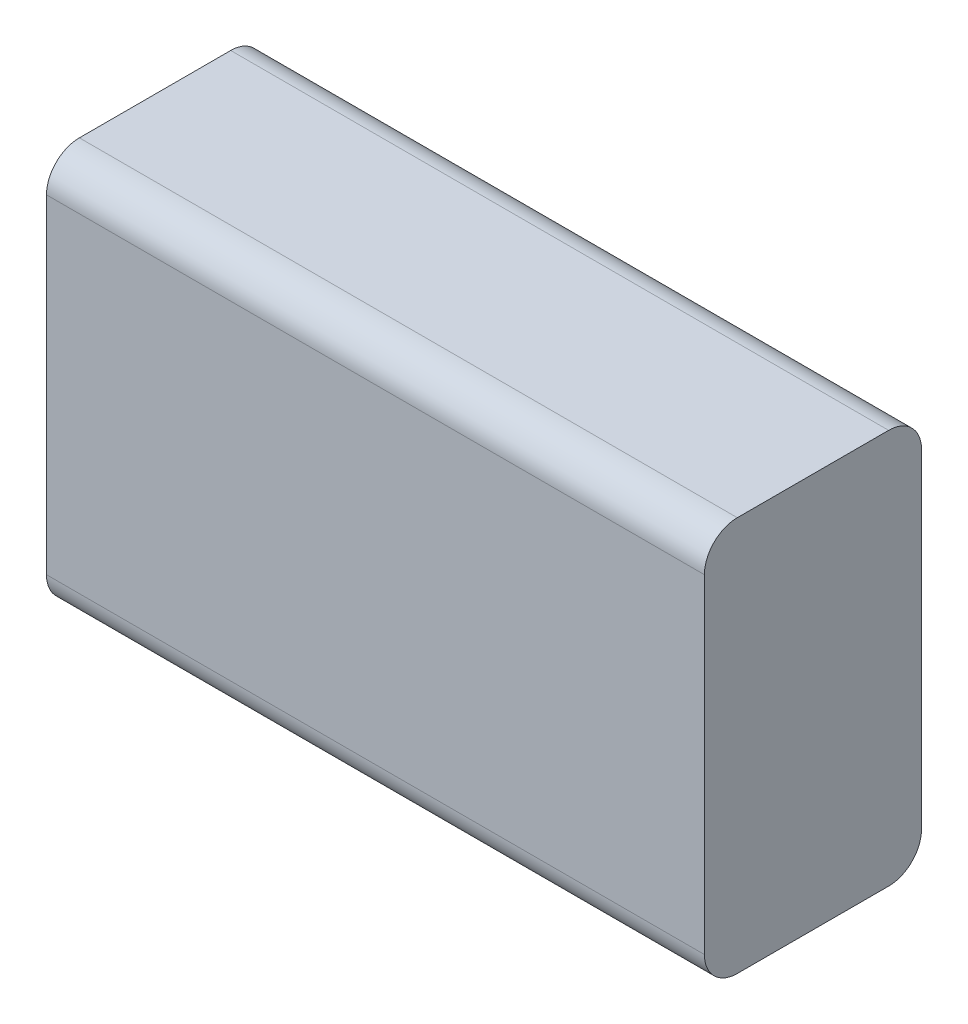
from build123d import *

# Parameters (mm, degrees)
SKETCH1_W           = 1
SKETCH1_H           = 0.33
BOSS_EXTRUDE1_DEPTH = 0.6
FILLET2_R           = 0.05


with BuildPart() as part:
    # Sketch1 → Boss-Extrude1 (new body)
    with BuildSketch(Plane(origin=(0, 0, 0), x_dir=(1, 0, 0), z_dir=(0, 1, 0))):
        with Locations((0.5, -0.165)):
            Rectangle(SKETCH1_W, SKETCH1_H)
    extrude(amount=BOSS_EXTRUDE1_DEPTH)

    # Fillet2
    fillet2_edges = [part.edges().sort_by_distance(p)[0] for p in [
        (0.5, 0.6, 0),
        (0.5, 0, 0),
        (0.5, 0, 0.33),
        (0.5, 0.6, 0.33),
    ]]
    fillet(fillet2_edges, radius=FILLET2_R)


solid = part.part
